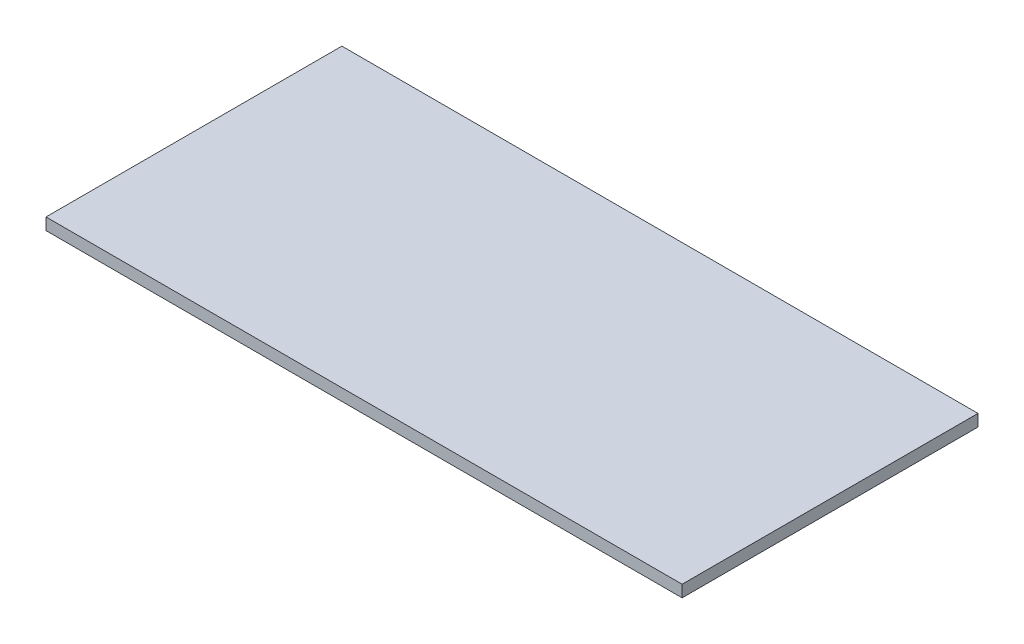
from build123d import *

# Parameters (mm, degrees)
SKETCH1_W      = 430
SKETCH1_H      = 200
EXTRUDE1_DEPTH = 8


with BuildPart() as part:
    # Sketch1 → Extrude1 (new body)
    with BuildSketch(Plane(origin=(0, 0, 0), x_dir=(1, 0, 0), z_dir=(0, 1, 0))):
        with Locations((215, 100)):
            Rectangle(SKETCH1_W, SKETCH1_H)
    extrude(amount=EXTRUDE1_DEPTH)


solid = part.part
